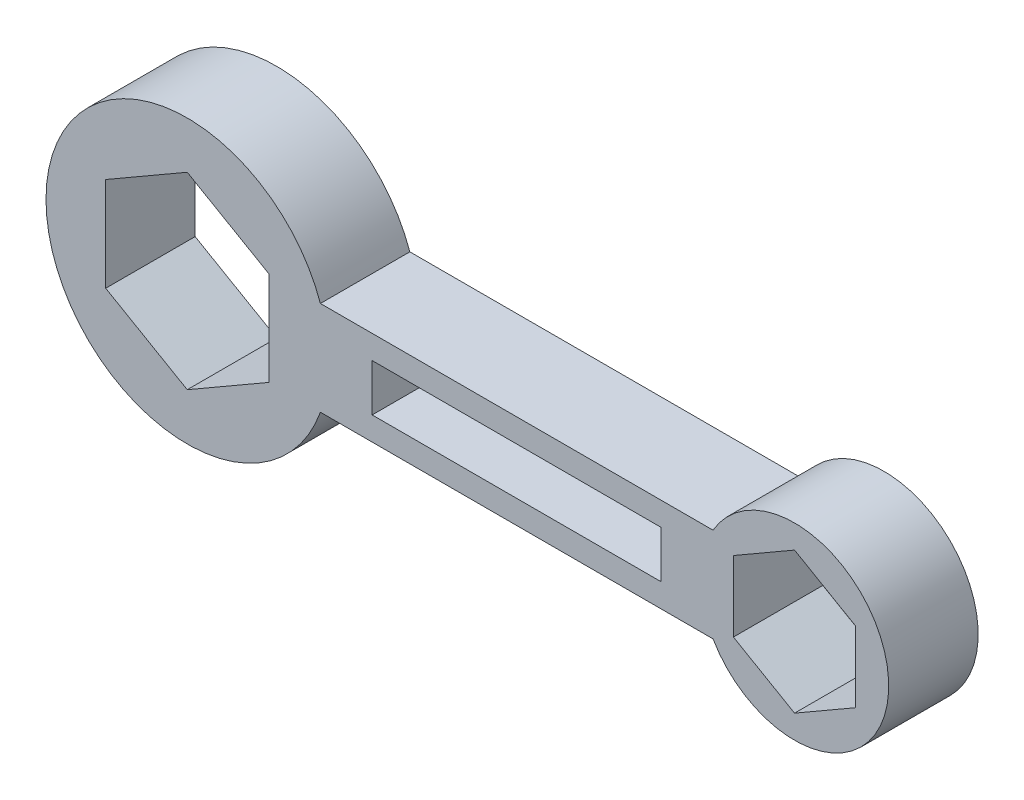
from build123d import *

# Parameters (mm, degrees)
BOSS_EXTRUDE4_DEPTH = 19
SKETCH3_W           = 61.395220677
SKETCH3_H           = 10
CUT_EXTRUDE2_DEPTH  = 19


with BuildPart() as part:
    # Sketch1 → Boss-Extrude4 (new body)
    with BuildSketch(Plane.XY):
        with BuildLine():
            Line((-45.044820263, -26.313108204), (38.350400414, -26.313108204))
            ThreePointArc((38.350400414, -26.313108204), (75.67090849, -16.313108204), (38.350400414, -6.313108204))
            Line((38.350400414, -6.313108204), (-45.044820263, -6.313108204))
            ThreePointArc((-45.044820263, -6.313108204), (-103.32909151, -16.313108204), (-45.044820263, -26.313108204))
        make_face()
    extrude(amount=BOSS_EXTRUDE4_DEPTH)

    # Sketch3 → Cut-Extrude2 (cut)
    with BuildSketch(Plane.XY.offset(19)):
        Polygon((-73.32909151, 3.686891796), (-90.649599586, -6.313108204), (-90.649599586, -26.313108204), (-73.32909151, -36.313108204), (-56.008583435, -26.313108204), (-56.008583435, -6.313108204), align=None)
        Polygon((55.67090849, -1.313108204), (42.680527433, -8.813108204), (42.680527433, -23.813108204), (55.67090849, -31.313108204), (68.661289547, -23.813108204), (68.661289547, -8.813108204), align=None)
        with Locations((-3.347209925, -16.313108204)):
            Rectangle(SKETCH3_W, SKETCH3_H)
    extrude(amount=-CUT_EXTRUDE2_DEPTH, mode=Mode.SUBTRACT)


solid = part.part
